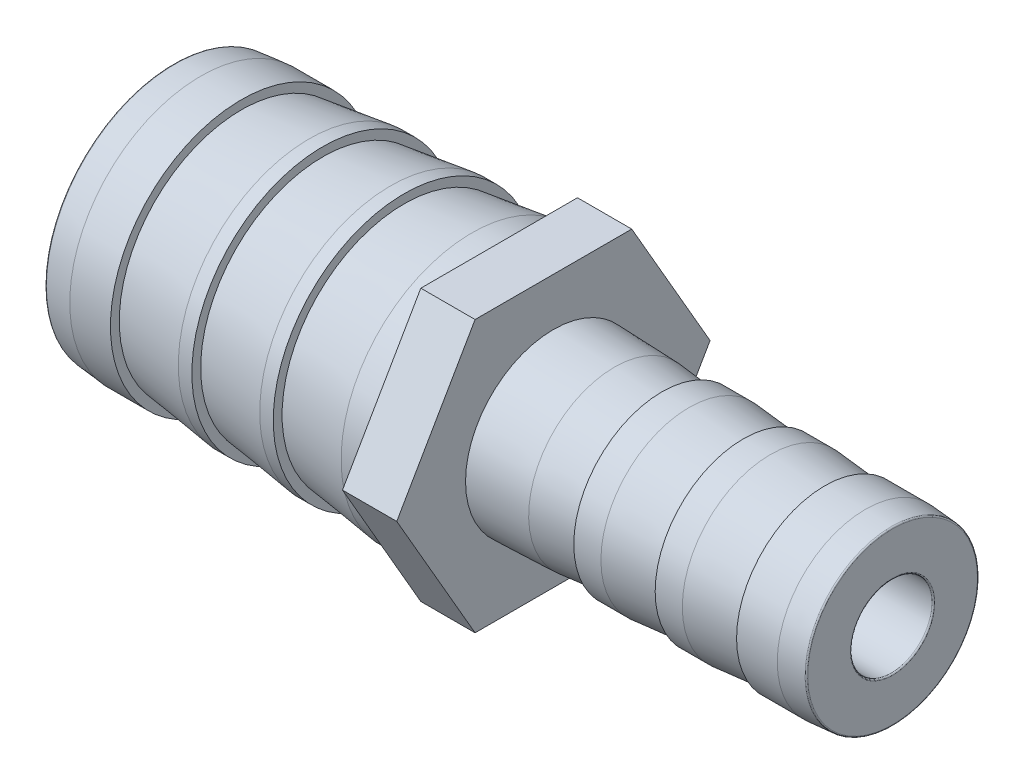
from build123d import *

# Parameters (mm, degrees)
BOSS_EXTRUDE1_DEPTH = 4
HOLE1_D             = 6
HOLE1_DEPTH         = 53
HOLE1_CBORE_D       = 16.8
HOLE1_CBORE_DEPTH   = 24
FILLET1_R           = 0.1
SCALE1_SCALE        = 0.92


with BuildPart() as part:
    # Sketch1 → Boss-Extrude1 (new body)
    with BuildSketch(Plane(origin=(2, 0, 0), x_dir=(0, 0, -1), z_dir=(1, 0, 0))):
        Polygon((11.547005384, 0), (5.773502692, 10), (-5.773502692, 10), (-11.547005384, 0), (-5.773502692, -10), (5.773502692, -10), align=None)
    extrude(amount=-BOSS_EXTRUDE1_DEPTH)

    # Sketch2 → Revolve1 (revolve)
    with BuildSketch(Plane.XY):
        Polygon((-26, 9.45), (-26, 0), (-2, 0), (-2, 9.65), (-4, 9.65), (-9, 9), (-9, 9.65), (-10, 9.65), (-15, 9), (-15, 9.65), (-16, 9.65), (-21, 9), (-21, 9.65), (-24, 9.65), align=None)
    revolve(axis=Axis((-26, 0, 0), (1, 0, 0)))

    # Sketch3 → Revolve2 (revolve)
    with BuildSketch(Plane.XY):
        Polygon((2, 6.477), (2, 0), (27, 0), (27, 6.35), (25, 6.5), (22, 6.5), (22, 6.15), (18, 6.5), (16, 6.5), (16, 6.15), (12, 6.5), (10, 6.5), (10, 5.977), (6.5, 6.327), align=None)
    revolve(axis=Axis((2, 0, 0), (1, 0, 0)))

    # Hole1
    with Locations(Plane.ZY.offset(26)):
        with Locations((0, 0)):
            CounterBoreHole(HOLE1_D / 2, HOLE1_CBORE_D / 2, HOLE1_CBORE_DEPTH, depth=HOLE1_DEPTH)

    # Fillet1
    fillet1_edges = [part.edges().sort_by_distance(p)[0] for p in [
        (-26, -9.45, 0),
        (27, -6.35, 0),
        (-26, 0, -8.4),
        (27, 0, 3),
    ]]
    fillet(fillet1_edges, radius=FILLET1_R)


with BuildPart() as part_1:
    # Scale1: scaled about (3.211544185, 0, 0)
    add(part.part.scale(SCALE1_SCALE).moved(Location((0.256923535, 0, 0))))


solid = part_1.part
